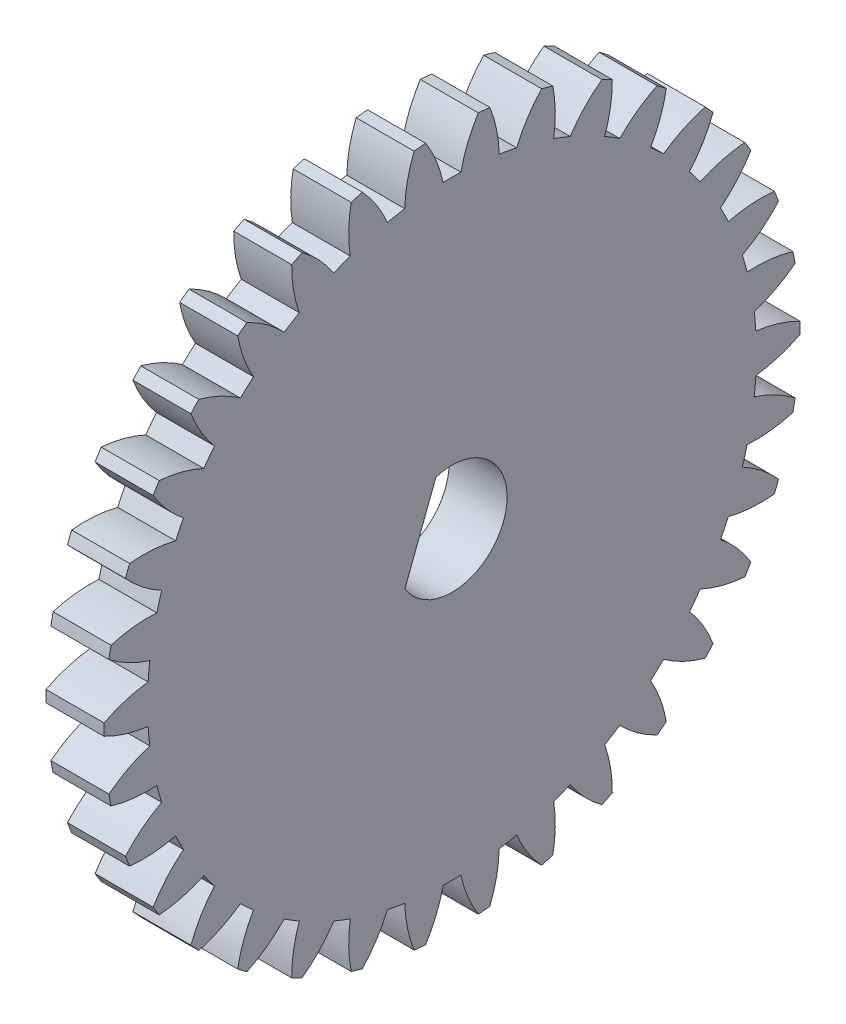
from build123d import *

# Parameters (mm, degrees)
BASPROSKE_W        = 3
BASPROSKE_H        = 18
TOOTHCUT_DEPTH     = 26.632011236
TEETHCUTS_COUNT    = 34
TEETHCUTS_ANGLE    = 349.411764706
CUT_EXTRUDE1_DEPTH = 26.595810004


with BuildPart() as part:
    # BasProSke → Base-Revolve (revolve)
    with BuildSketch(Plane(origin=(0, 0, 0), x_dir=(1, 0, 0), z_dir=(0, 1, 0)), mode=Mode.PRIVATE) as base_revolve_sk:
        with Locations((1.5, 9)):
            Rectangle(BASPROSKE_W, BASPROSKE_H)
    revolve(base_revolve_sk.sketch.rotate(Axis((-10, 0, 0), (1, 0, 0)), 180), axis=Axis((-10, 0, 0), (1, 0, 0)))

    # TooCutSke → ToothCut (cut, through all)
    with BuildSketch(Plane(origin=(0, 0, 0), x_dir=(0, 0, -1), z_dir=(1, 0, 0))):
        with BuildLine():
            ThreePointArc((0.458149848, 15.742334634), (0, 15.749), (-0.458149848, 15.742334634))
            ThreePointArc((-0.458149848, 15.742334634), (-0.818018246, 16.898604037), (-1.377276242, 17.972705843))
            ThreePointArc((-1.377276242, 17.972705843), (0, 18.0254), (1.377276242, 17.972705843))
            ThreePointArc((1.377276242, 17.972705843), (0.818018246, 16.898604037), (0.458149848, 15.742334634))
        make_face()
    toothcut = extrude(amount=TOOTHCUT_DEPTH, mode=Mode.SUBTRACT)

    # TeethCuts: ToothCut ×34 about axis
    teethcuts_axis = Axis((-10, 0, 0), (1, 0, 0))
    for i in range(1, TEETHCUTS_COUNT):
        add(toothcut.rotate(teethcuts_axis, i * TEETHCUTS_ANGLE / (TEETHCUTS_COUNT - 1)), mode=Mode.SUBTRACT)

    # Sketch1 → Cut-Extrude1 (cut, through all)
    with BuildSketch(Plane(origin=(3, 0, 0), x_dir=(0, 0, -1), z_dir=(1, 0, 0))):
        with BuildLine():
            Line((-0.831821548, 2.725907723), (-2.436692771, -1.478184136))
            ThreePointArc((-2.436692771, -1.478184136), (2.662591511, -1.016418441), (-0.831821548, 2.725907723))
        make_face()
    extrude(amount=-CUT_EXTRUDE1_DEPTH, mode=Mode.SUBTRACT)


solid = part.part
